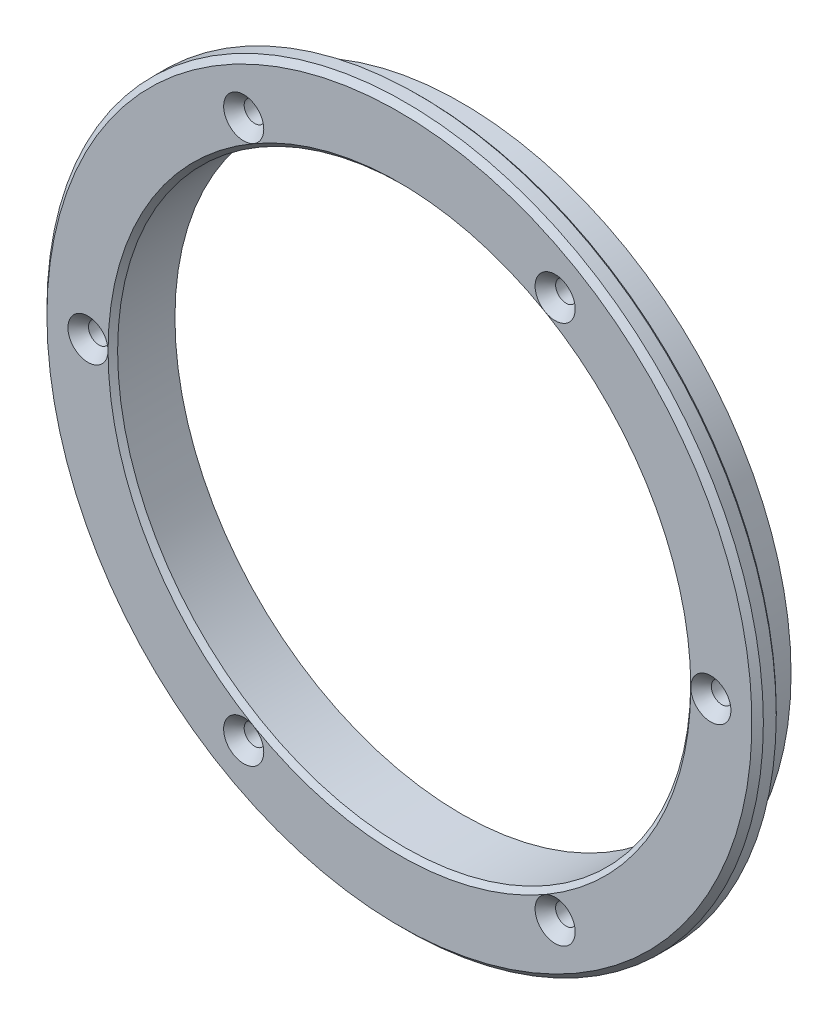
from build123d import *

# Parameters (mm, degrees)
SKETCH1_R         = 47.625
EXTRUDE1_DEPTH    = 8.255
SKETCH2_R         = 38.1
EXTRUDE2_DEPTH    = 8.255
SKETCH3_W         = 3.81
SKETCH3_H         = 5.3975
CHAMFER1_SIZE     = 0.635
HOLE1_D           = 2.794
HOLE1_DEPTH       = 8.255
HOLE1_CSINK_D     = 5.334
HOLE1_CSINK_ANGLE = 82
HOLE2_D           = 2.794
HOLE2_DEPTH       = 8.255
HOLE2_CSINK_D     = 5.334
HOLE2_CSINK_ANGLE = 82
HOLE3_D           = 2.794
HOLE3_DEPTH       = 8.255
HOLE3_CSINK_D     = 5.334
HOLE3_CSINK_ANGLE = 82
HOLE4_D           = 2.794
HOLE4_DEPTH       = 8.255
HOLE4_CSINK_D     = 5.334
HOLE4_CSINK_ANGLE = 82
HOLE5_D           = 2.794
HOLE5_DEPTH       = 8.255
HOLE5_CSINK_D     = 5.334
HOLE5_CSINK_ANGLE = 82
HOLE6_D           = 2.794
HOLE6_DEPTH       = 8.255
HOLE6_CSINK_D     = 5.334
HOLE6_CSINK_ANGLE = 82
CHAMFER2_SIZE     = 0.381
CHAMFER3_SIZE     = 0.762


with BuildPart() as part:
    # Sketch1 → Extrude1 (new body)
    with BuildSketch(Plane.XY.offset(12.7)):
        Circle(SKETCH1_R)
    extrude(amount=-EXTRUDE1_DEPTH)

    # Sketch2 → Extrude2 (cut)
    with BuildSketch(Plane.XY.offset(12.7)):
        Circle(SKETCH2_R)
    extrude(amount=-EXTRUDE2_DEPTH, mode=Mode.SUBTRACT)

    # Sketch3 → Cut-Revolve1 (revolve, cut)
    with BuildSketch(Plane.XZ):
        with Locations((45.72, 7.14375)):
            Rectangle(SKETCH3_W, SKETCH3_H)
    revolve(axis=Axis((0, 0, 9.8425), (0, 0, -1)), mode=Mode.SUBTRACT)

    # Chamfer1
    chamfer1_edges = [part.edges().sort_by_distance(p)[0] for p in [
        (-38.1, 0, 12.7),
    ]]
    chamfer(chamfer1_edges, length=CHAMFER1_SIZE)

    # Hole1
    with Locations(Plane.XY.offset(12.7)):
        with Locations((-20.701, -35.855183767)):
            CounterSinkHole(HOLE1_D / 2, HOLE1_CSINK_D / 2, depth=HOLE1_DEPTH, counter_sink_angle=HOLE1_CSINK_ANGLE)

    # Hole2
    with Locations(Plane.XY.offset(12.7)):
        with Locations((-41.402, 0)):
            CounterSinkHole(HOLE2_D / 2, HOLE2_CSINK_D / 2, depth=HOLE2_DEPTH, counter_sink_angle=HOLE2_CSINK_ANGLE)

    # Hole3
    with Locations(Plane.XY.offset(12.7)):
        with Locations((-20.701, 35.855183767)):
            CounterSinkHole(HOLE3_D / 2, HOLE3_CSINK_D / 2, depth=HOLE3_DEPTH, counter_sink_angle=HOLE3_CSINK_ANGLE)

    # Hole4
    with Locations(Plane.XY.offset(12.7)):
        with Locations((20.701, 35.855183767)):
            CounterSinkHole(HOLE4_D / 2, HOLE4_CSINK_D / 2, depth=HOLE4_DEPTH, counter_sink_angle=HOLE4_CSINK_ANGLE)

    # Hole5
    with Locations(Plane.XY.offset(12.7)):
        with Locations((20.701, -35.855183767)):
            CounterSinkHole(HOLE5_D / 2, HOLE5_CSINK_D / 2, depth=HOLE5_DEPTH, counter_sink_angle=HOLE5_CSINK_ANGLE)

    # Hole6
    with Locations(Plane.XY.offset(12.7)):
        with Locations((41.402, 0)):
            CounterSinkHole(HOLE6_D / 2, HOLE6_CSINK_D / 2, depth=HOLE6_DEPTH, counter_sink_angle=HOLE6_CSINK_ANGLE)

    # Chamfer2
    chamfer2_edges = [part.edges().sort_by_distance(p)[0] for p in [
        (-47.625, 0, 9.8425),
    ]]
    chamfer(chamfer2_edges, length=CHAMFER2_SIZE)

    # Chamfer3
    chamfer3_edges = [part.edges().sort_by_distance(p)[0] for p in [
        (-47.625, 0, 12.7),
    ]]
    chamfer(chamfer3_edges, length=CHAMFER3_SIZE)


solid = part.part
